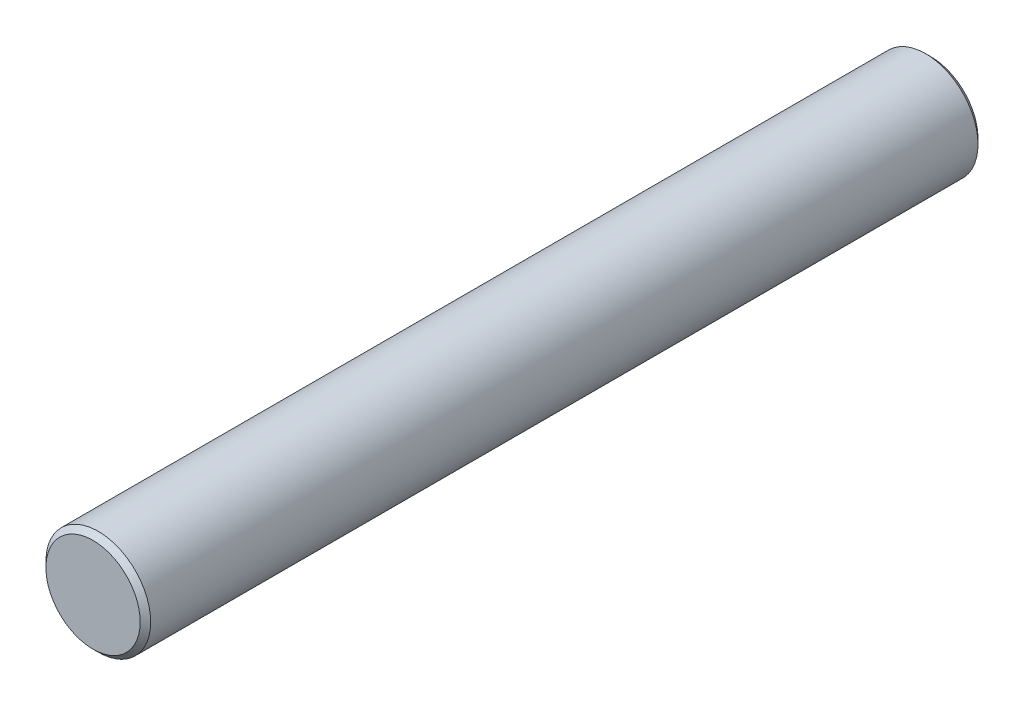
from build123d import *

# Parameters (mm, degrees)
ESQUISSE1_R          = 2.5
BASE_EXTRUSION_DEPTH = 40
CHANFREIN1_SIZE      = 0.25


with BuildPart() as part:
    # Esquisse1 → Base-Extrusion (new body)
    with BuildSketch(Plane.XY):
        Circle(ESQUISSE1_R)
    extrude(amount=BASE_EXTRUSION_DEPTH)

    # Chanfrein1
    chanfrein1_edges = [part.edges().sort_by_distance(p)[0] for p in [
        (-2.5, 0, 0),
        (-2.5, 0, 40),
    ]]
    chamfer(chanfrein1_edges, length=CHANFREIN1_SIZE)


solid = part.part
